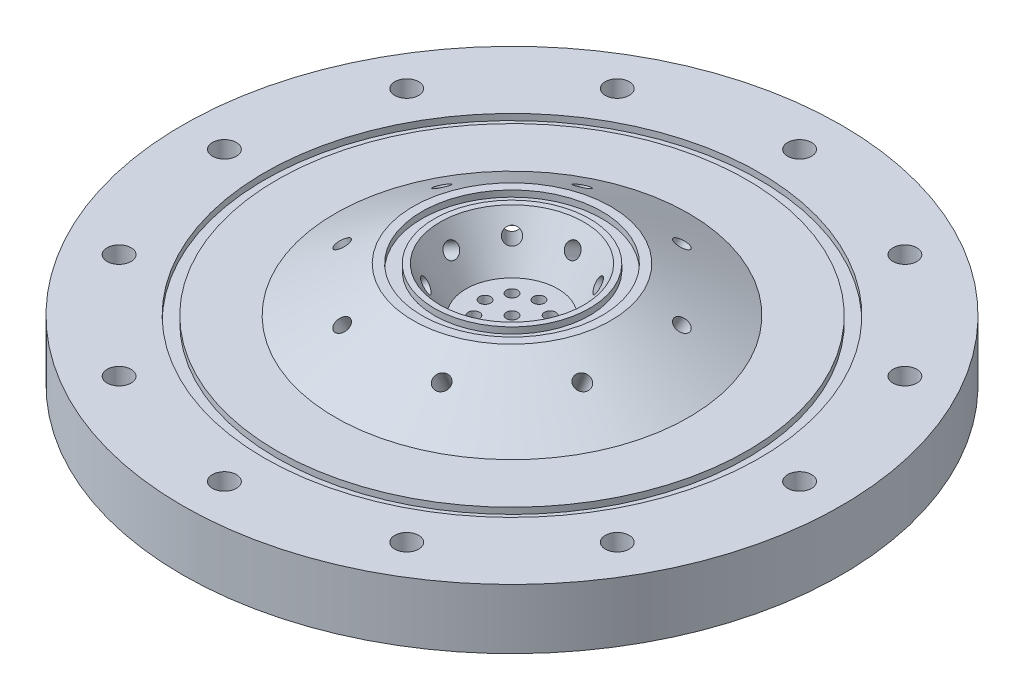
from build123d import *

# Parameters (mm, degrees)
SKETCH1_R           = 69.85
BOSS_EXTRUDE1_DEPTH = 12.7
SKETCH2_R           = 20.955
SKETCH2_R_2         = 15.24
BOSS_EXTRUDE2_DEPTH = 9.525
CUT_EXTRUDE5_START  = -3.175
SKETCH10_R          = 1.5875
CUT_EXTRUDE5_DEPTH  = 34.671
CUT_EXTRUDE6_START  = -3.175
SKETCH11_R          = 1.5875
CUT_EXTRUDE6_DEPTH  = 22.225
CIRPATTERN1_COUNT   = 8
SKETCH12_R          = 2.54
CUT_EXTRUDE7_DEPTH  = 13.7
CIRPATTERN2_COUNT   = 12
SKETCH13_R          = 41.275
SKETCH13_R_2        = 33.02
SKETCH13_R_3        = 25.4
SKETCH13_R_4        = 14.2875
SKETCH13_R_5        = 7.62
CUT_EXTRUDE10_DEPTH = 6.35
SKETCH15_R          = 1.190625
CUT_EXTRUDE11_DEPTH = 13.7000001
CIRPATTERN3_COUNT   = 8
SKETCH16_R          = 30.2133
SKETCH16_R_2        = 27.5717
CUT_EXTRUDE12_DEPTH = 1.3208
SKETCH17_R          = 11.9507
SKETCH17_R_2        = 9.3091
CUT_EXTRUDE13_DEPTH = 1.3208
SKETCH18_R          = 52.4383
SKETCH18_R_2        = 49.7967
CUT_EXTRUDE14_DEPTH = 1.3208
SKETCH19_R          = 52.4383
SKETCH19_R_2        = 49.7967
CUT_EXTRUDE15_DEPTH = 1.3208
SKETCH20_R          = 19.1008
SKETCH20_R_2        = 16.4592
CUT_EXTRUDE16_DEPTH = 1.3208
SKETCH21_R          = 1.190625
CUT_EXTRUDE17_DEPTH = 13.7000001


with BuildPart() as part:
    # Sketch1 → Boss-Extrude1 (new body)
    with BuildSketch(Plane(origin=(0, 0, 0), x_dir=(1, 0, 0), z_dir=(0, 1, 0))):
        Circle(SKETCH1_R)
    extrude(amount=BOSS_EXTRUDE1_DEPTH)

    # Sketch2 → Boss-Extrude2 (add)
    with BuildSketch(Plane(origin=(0, 12.7, 0), x_dir=(1, 0, 0), z_dir=(0, 1, 0))):
        Circle(SKETCH2_R)
        Circle(SKETCH2_R_2, mode=Mode.SUBTRACT)
    extrude(amount=BOSS_EXTRUDE2_DEPTH)

    # Sketch7 → Revolve2 (revolve)
    with BuildSketch(Plane.XY):
        Polygon((-15.24, 22.225), (-15.24, 12.7), (-9.740738686, 12.7), align=None)
    revolve(axis=Axis((0, 0, 0), (0, 1, 0)))

    # Sketch9 → Revolve3 (revolve)
    with BuildSketch(Plane(origin=(0, 0, 0), x_dir=(-0.923879533, 0, 0.382683432), z_dir=(-0.382683432, 0, -0.923879533))):
        Polygon((-20.955, 22.225), (-20.955, 12.7), (-37.452783942, 12.7), align=None)
    revolve(axis=Axis((0, 0, 0), (0, 1, 0)))

    # Sketch10 → Cut-Extrude5 (cut)
    with BuildSketch(Plane(origin=(-1.8062927, -1.042863577, 0), x_dir=(0.5, -0.866025404, 0), z_dir=(-0.866025404, -0.5, 0)).offset(CUT_EXTRUDE5_START)):
        with Locations((-22.218891971, 0)):
            Circle(SKETCH10_R)
    cut_extrude5 = extrude(amount=CUT_EXTRUDE5_DEPTH, mode=Mode.SUBTRACT)

    # Sketch11 → Cut-Extrude6 (cut)
    with BuildSketch(Plane(origin=(13.731120102, 25.742531168, -5.687616173), x_dir=(0.800103145, -0.5, -0.331413574), z_dir=(-0.461939766, -0.866025404, 0.191341716)).offset(CUT_EXTRUDE6_START)):
        with Locations((14.655062336, 0)):
            Circle(SKETCH11_R)
    cut_extrude6 = extrude(amount=CUT_EXTRUDE6_DEPTH, mode=Mode.SUBTRACT)

    # CirPattern1: Cut-Extrude5, Cut-Extrude6 ×8 about axis
    cirpattern1_axis = Axis((0, 0, 0), (0, 1, 0))
    for i in range(1, CIRPATTERN1_COUNT):
        add(cut_extrude5.rotate(cirpattern1_axis, i * 360 / CIRPATTERN1_COUNT), mode=Mode.SUBTRACT)
        add(cut_extrude6.rotate(cirpattern1_axis, i * 360 / CIRPATTERN1_COUNT), mode=Mode.SUBTRACT)

    # Sketch12 → Cut-Extrude7 (cut, through all)
    with BuildSketch(Plane(origin=(0, 12.7, 0), x_dir=(1, 0, 0), z_dir=(0, 1, 0))):
        with Locations((60.96, 0)):
            Circle(SKETCH12_R)
    cut_extrude7 = extrude(amount=-CUT_EXTRUDE7_DEPTH, mode=Mode.SUBTRACT)

    # CirPattern2: Cut-Extrude7 ×12 about axis
    cirpattern2_axis = Axis((0, 0, 0), (0, 1, 0))
    for i in range(1, CIRPATTERN2_COUNT):
        add(cut_extrude7.rotate(cirpattern2_axis, i * 360 / CIRPATTERN2_COUNT), mode=Mode.SUBTRACT)

    # Sketch13 → Cut-Extrude10 (cut)
    with BuildSketch(Plane.XZ):
        Circle(SKETCH13_R)
        Circle(SKETCH13_R_2, mode=Mode.SUBTRACT)
        Circle(SKETCH13_R_3)
        Circle(SKETCH13_R_4, mode=Mode.SUBTRACT)
        Circle(SKETCH13_R_5)
    extrude(amount=-CUT_EXTRUDE10_DEPTH, mode=Mode.SUBTRACT)

    # Sketch15 → Cut-Extrude11 (cut, through all)
    with BuildSketch(Plane(origin=(0, 12.7, 0), x_dir=(1, 0, 0), z_dir=(0, 1, 0))):
        with Locations((0, 5.715)):
            Circle(SKETCH15_R)
    cut_extrude11 = extrude(amount=-CUT_EXTRUDE11_DEPTH, mode=Mode.SUBTRACT)

    # CirPattern3: Cut-Extrude11 ×8 about axis
    cirpattern3_axis = Axis((0, 0, 0), (0, 1, 0))
    for i in range(1, CIRPATTERN3_COUNT):
        add(cut_extrude11.rotate(cirpattern3_axis, i * 360 / CIRPATTERN3_COUNT), mode=Mode.SUBTRACT)

    # Sketch16 → Cut-Extrude12 (cut)
    with BuildSketch(Plane.XZ):
        Circle(SKETCH16_R)
        Circle(SKETCH16_R_2, mode=Mode.SUBTRACT)
    extrude(amount=-CUT_EXTRUDE12_DEPTH, mode=Mode.SUBTRACT)

    # Sketch17 → Cut-Extrude13 (cut)
    with BuildSketch(Plane.XZ):
        Circle(SKETCH17_R)
        Circle(SKETCH17_R_2, mode=Mode.SUBTRACT)
    extrude(amount=-CUT_EXTRUDE13_DEPTH, mode=Mode.SUBTRACT)

    # Sketch18 → Cut-Extrude14 (cut)
    with BuildSketch(Plane(origin=(0, 12.7, 0), x_dir=(1, 0, 0), z_dir=(0, 1, 0))):
        Circle(SKETCH18_R)
        Circle(SKETCH18_R_2, mode=Mode.SUBTRACT)
    extrude(amount=-CUT_EXTRUDE14_DEPTH, mode=Mode.SUBTRACT)

    # Sketch19 → Cut-Extrude15 (cut)
    with BuildSketch(Plane.XZ):
        Circle(SKETCH19_R)
        Circle(SKETCH19_R_2, mode=Mode.SUBTRACT)
    extrude(amount=-CUT_EXTRUDE15_DEPTH, mode=Mode.SUBTRACT)

    # Sketch20 → Cut-Extrude16 (cut)
    with BuildSketch(Plane(origin=(0, 22.225, 0), x_dir=(1, 0, 0), z_dir=(0, 1, 0))):
        Circle(SKETCH20_R)
        Circle(SKETCH20_R_2, mode=Mode.SUBTRACT)
    extrude(amount=-CUT_EXTRUDE16_DEPTH, mode=Mode.SUBTRACT)

    # Sketch21 → Cut-Extrude17 (cut, through all)
    with BuildSketch(Plane(origin=(0, 12.7, 0), x_dir=(1, 0, 0), z_dir=(0, 1, 0))):
        Circle(SKETCH21_R)
    extrude(amount=-CUT_EXTRUDE17_DEPTH, mode=Mode.SUBTRACT)


solid = part.part
